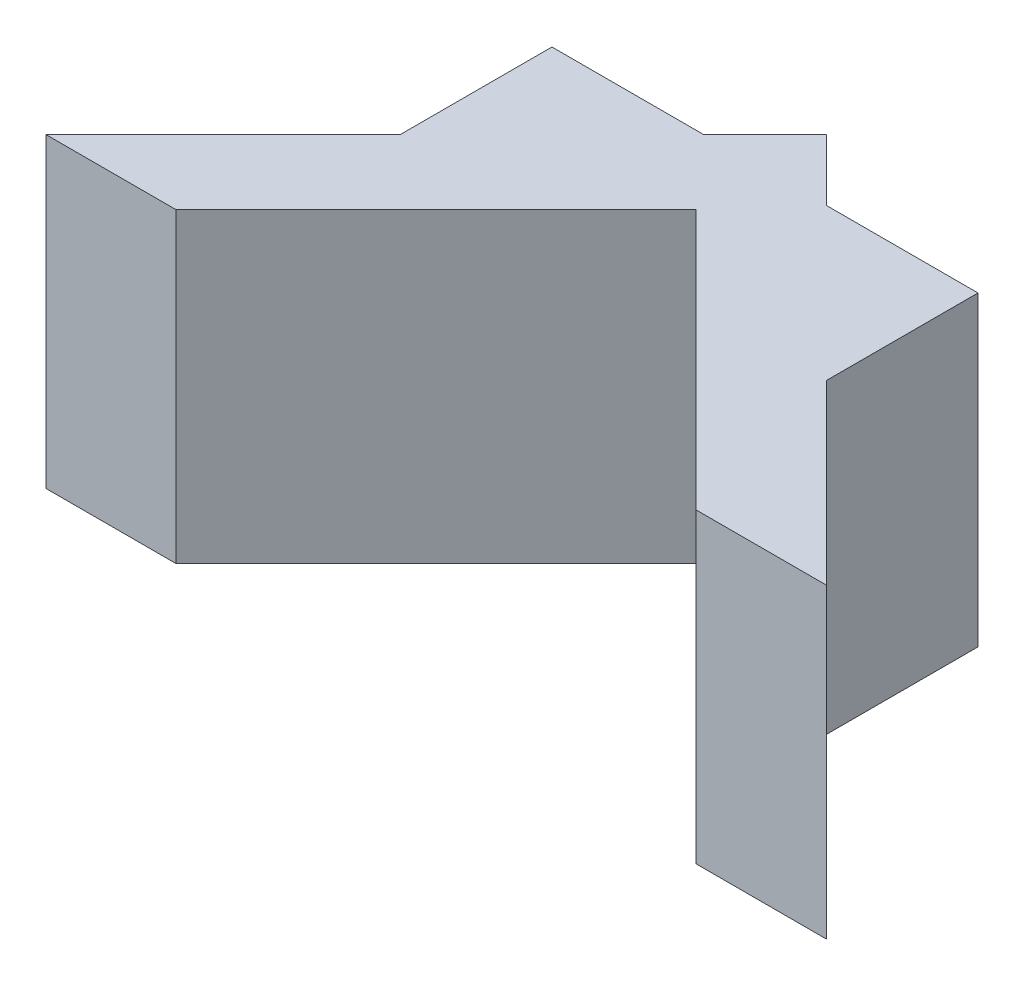
from build123d import *

# Parameters (mm, degrees)
EXTRUDE_1_DEPTH     = 10
EXTRUDE_2_DEPTH     = 10
SKETCH_5_W          = 3.14
SKETCH_5_H          = 5.14
CUT_EXTRUDE_1_DEPTH = 3
SCALE_1_SCALE       = 1.5


with BuildPart() as part:
    # 스케치2 → 보스-돌출1 (new body)
    with BuildSketch(Plane(origin=(0, 0, 0), x_dir=(1, 0, 0), z_dir=(0, 1, 0))):
        Polygon((8.485281374, -8.485281374), (0, 0), (-8.485281374, -8.485281374), (-12.727922061, -8.485281374), (0, 4.242640687), (12.727922061, -8.485281374), align=None)
    extrude(amount=EXTRUDE_1_DEPTH)

    # 스케치3 → 보스-돌출2 (add)
    with BuildSketch(Plane(origin=(0, 10, 0), x_dir=(1, 0, 0), z_dir=(0, 1, 0))):
        Polygon((-6.949747468, -2.707106781), (-2, 2.242640687), (-6.949747468, 2.242640687), align=None)
        Polygon((2, 2.242640687), (6.949747468, -2.707106781), (6.949747468, 2.242640687), align=None)
    extrude(amount=-EXTRUDE_2_DEPTH)

    # 스케치5 → 컷-돌출1 (cut)
    with BuildSketch(Plane(origin=(0, 0, -2.242640687), x_dir=(-1, 0, 0), z_dir=(0, 0, -1))):
        with Locations((-4.57, 5)):
            Rectangle(SKETCH_5_W, SKETCH_5_H)
        with Locations((4.57, 5)):
            Rectangle(SKETCH_5_W, SKETCH_5_H)
    extrude(amount=-CUT_EXTRUDE_1_DEPTH, mode=Mode.SUBTRACT)


with BuildPart() as part_1:
    # 축척1: scaled about (0, 5, 2.601544192)
    add(part.part.scale(SCALE_1_SCALE).moved(Location((0, -2.5, -1.300772096))))


solid = part_1.part
